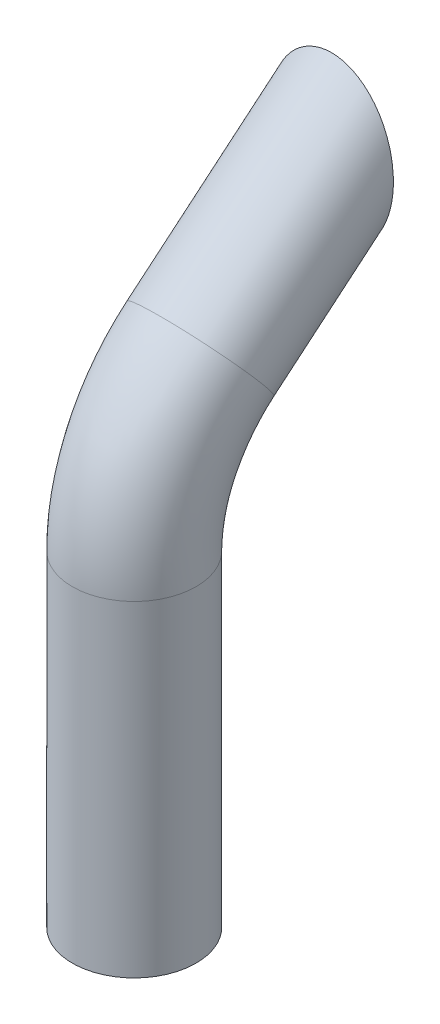
from build123d import *

# Parameters (mm, degrees)
SKETCH2_R          = 30
SKETCH2_R_2        = 27
SKETCH3_W          = 78.445279823
SKETCH3_H          = 88.088780511
CUT_EXTRUDE2_DEPTH = 45


with BuildPart() as part:
    # Sweep-Thin1: sweep along a path in Sketch1
    with BuildLine(Plane(origin=(0, 0, 0), x_dir=(0, 0, -1), z_dir=(1, 0, 0))) as sweep_thin1_path:
        Line((0, 0), (-82.75755134, -69.441830806))
        ThreePointArc((-82.75755134, -69.441830806), (-106.474367301, -100.35018713), (-114.906666468, -138.385830687))
        Line((-114.906666468, -138.385830687), (-114.906666468, -296.418141453))
    # Sketch2 → Sweep-Thin1 (sweep)
    with BuildSketch(Plane(origin=(0, 0, 0), x_dir=(1, 0, 0), z_dir=(0, -0.64278761, 0.766044443))):
        Circle(SKETCH2_R)
        Circle(SKETCH2_R_2, mode=Mode.SUBTRACT)
    sweep(path=sweep_thin1_path.line)

    # Sketch3 → Cut-Extrude2 (cut, symmetric)
    with BuildSketch(Plane(origin=(0, 0, 0), x_dir=(0, 0, -1), z_dir=(1, 0, 0))):
        with Locations((19.93901162, -21.063056961)):
            Rectangle(SKETCH3_W, SKETCH3_H)
    extrude(amount=CUT_EXTRUDE2_DEPTH, both=True, mode=Mode.SUBTRACT)


solid = part.part
